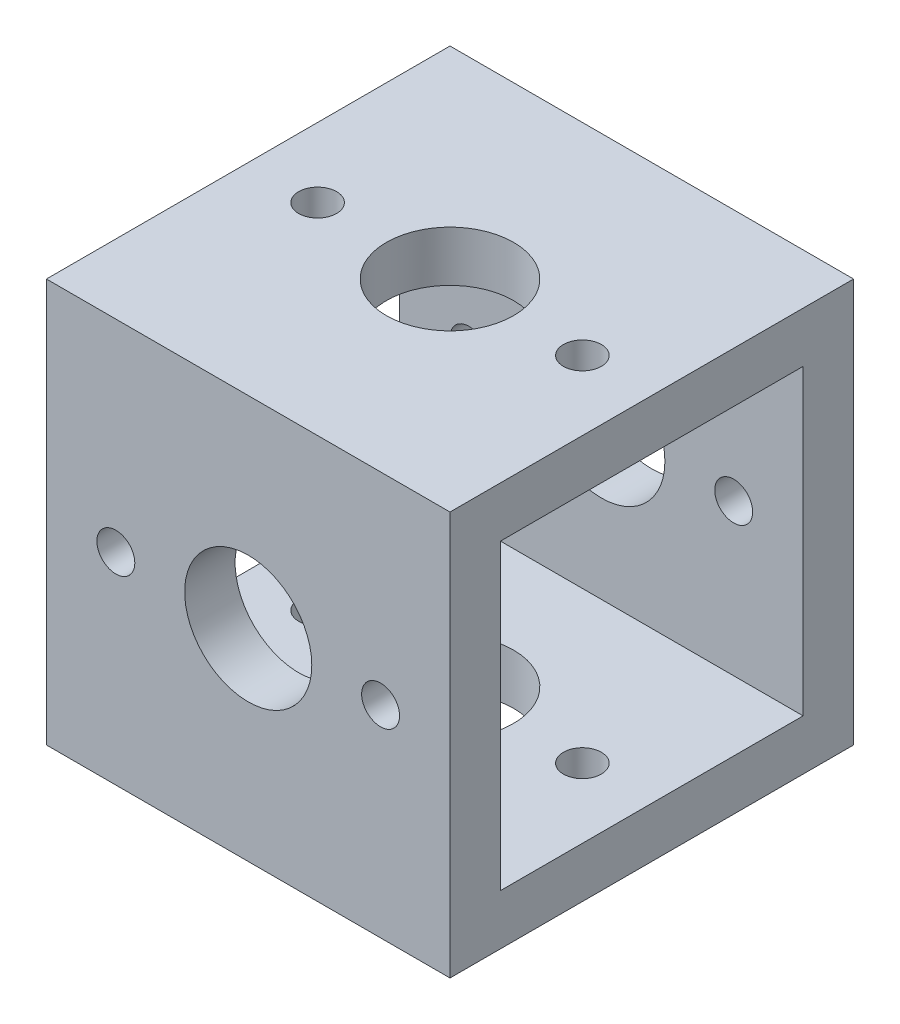
from build123d import *

# Parameters (mm, degrees)
SKETCH1_W               = 25.4
SKETCH1_H               = 25.4
SKETCH1_W_2             = 19.05
SKETCH1_H_2             = 19.05
EXTRUDE1_DEPTH          = 25.4
SKETCH3_R               = 4.0005
SKETCH3_R_2             = 1.1938
CUT_EXTRUDE1_DEPTH      = 25.6126
CUT_EXTRUDE1_DEPTH_BACK = 25.4
SKETCH2_R               = 1.1938
SKETCH2_R_2             = 4.0005
CUT_EXTRUDE2_DEPTH      = 25.6126
CUT_EXTRUDE2_DEPTH_BACK = 25.4


with BuildPart() as part:
    # Sketch1 → Extrude1 (new body)
    with BuildSketch(Plane(origin=(0, 0, 0), x_dir=(0, 0, -1), z_dir=(1, 0, 0))):
        with Locations((-11.9126, 11.9126)):
            Rectangle(SKETCH1_W, SKETCH1_H)
        with Locations((-11.9126, 11.9126)):
            Rectangle(SKETCH1_W_2, SKETCH1_H_2, mode=Mode.SUBTRACT)
    extrude(amount=EXTRUDE1_DEPTH)

    # Sketch3 → Cut-Extrude1 (cut, two sides)
    with BuildSketch(Plane(origin=(0, 0, 0), x_dir=(1, 0, 0), z_dir=(0, 1, 0))) as cut_extrude1_sk:
        with Locations(Location((12.7, -11.9126, 0), (0, 0, 90))):  # turned: the seam where the file's is
            Circle(SKETCH3_R)
        with Locations(Location((4.3688, -11.9126, 0), (0, 0, 90))):  # turned: the seam where the file's is
            Circle(SKETCH3_R_2)
        with Locations(Location((21.0312, -11.9126, 0), (0, 0, 90))):  # turned: the seam where the file's is
            Circle(SKETCH3_R_2)
    extrude(amount=CUT_EXTRUDE1_DEPTH, mode=Mode.SUBTRACT)
    extrude(cut_extrude1_sk.sketch, amount=-CUT_EXTRUDE1_DEPTH_BACK, mode=Mode.SUBTRACT)

    # Sketch2 → Cut-Extrude2 (cut, two sides)
    with BuildSketch(Plane.XY) as cut_extrude2_sk:
        with Locations((4.3688, 11.9126)):
            Circle(SKETCH2_R)
        with Locations((21.0312, 11.9126)):
            Circle(SKETCH2_R)
        with Locations((12.7, 11.9126)):
            Circle(SKETCH2_R_2)
    extrude(amount=CUT_EXTRUDE2_DEPTH, mode=Mode.SUBTRACT)
    extrude(cut_extrude2_sk.sketch, amount=-CUT_EXTRUDE2_DEPTH_BACK, mode=Mode.SUBTRACT)


solid = part.part
